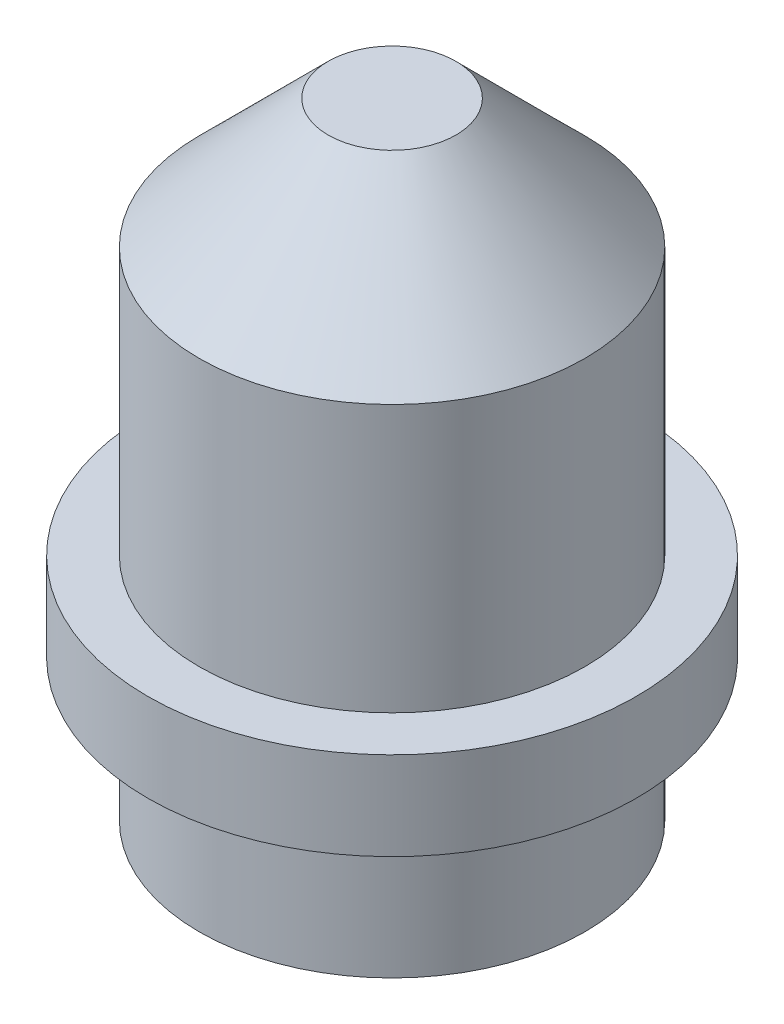
from build123d import *


with BuildPart() as part:
    # Эскиз1 → Повернуть1 (revolve)
    with BuildSketch(Plane.XY):
        Polygon((-3.8, 3.572013722), (-3.8, 2.2), (-3, 2.2), (-3, 0), (0, 0), (0, 9.73129778), (-0.99394651, 9.73129778), (-3, 7.72524429), (-3, 3.572013722), align=None)
    revolve(axis=Axis((0, 14.588041347, 0), (0, -1, 0)))


solid = part.part
